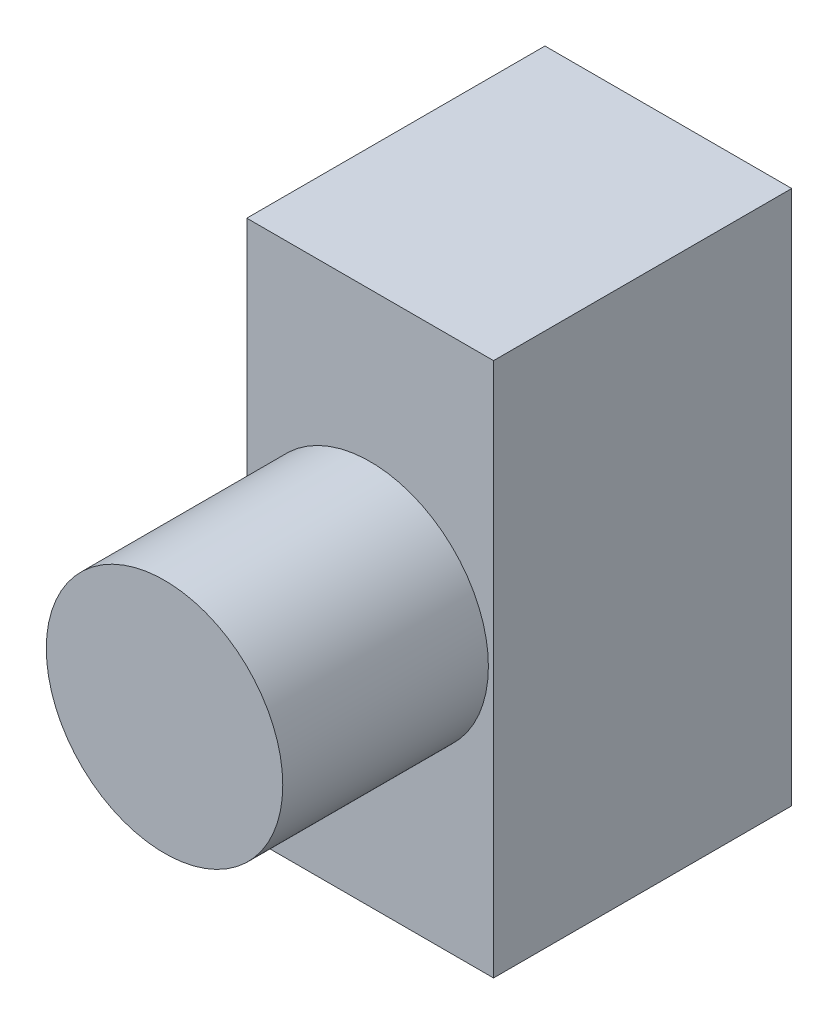
from build123d import *

# Parameters (mm, degrees)
SKETCH1_W           = 12
SKETCH1_H           = 26
BOSS_EXTRUDE1_DEPTH = 14.5
SKETCH1_3_R         = 5.75
BOSS_EXTRUDE2_DEPTH = 10


with BuildPart() as part:
    # Sketch1 → Boss-Extrude1 (new body)
    with BuildSketch(Plane.XY):
        Rectangle(SKETCH1_W, SKETCH1_H)
    extrude(amount=-BOSS_EXTRUDE1_DEPTH)

    # Sketch1_3 → Boss-Extrude2 (add)
    with BuildSketch(Plane.XY):
        Circle(SKETCH1_3_R)
    extrude(amount=BOSS_EXTRUDE2_DEPTH)


solid = part.part
